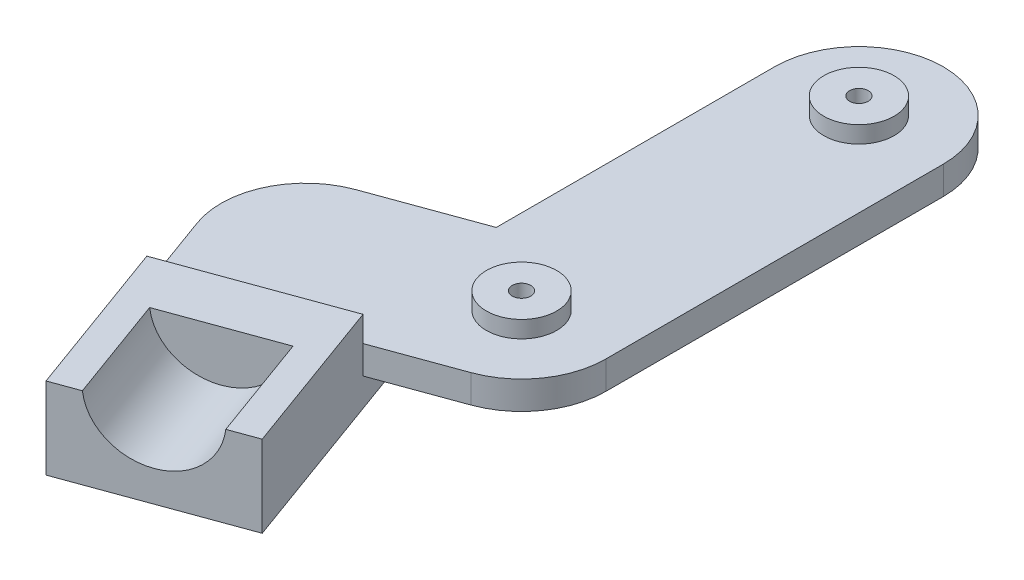
from build123d import *

# Parameters (mm, degrees)
EXTRUDE_1_DEPTH        = 5
SKETCH_2_R             = 6.25
EXTRUDE_2_DEPTH        = 3
HOLE_WIZARD_M4_1_D     = 3.3
HOLE_WIZARD_M4_1_DEPTH = 5
HOLE_WIZARD_M4_1_TIP   = 0.991420021
EXTRUDE_3_DEPTH        = 5
EXTRUDE_4_DEPTH        = 5
EXTRUDE_4_DEPTH_BACK   = 5
EXTRUDE_5_DEPTH        = 4.5
SKETCH_12_R            = 10
CUT_EXTRUDE_1_DEPTH    = 20


with BuildPart() as part:
    # 스케치1 → 보스-돌출1 (new body)
    with BuildSketch(Plane(origin=(0, 0, 0), x_dir=(1, 0, 0), z_dir=(0, 1, 0))):
        with BuildLine():
            Line((-15, 0), (-15, 60))
            ThreePointArc((-15, 60), (0, 75), (15, 60))
            Line((15, 60), (15, 0))
            ThreePointArc((15, 0), (0, -15), (-15, 0))
        make_face()
    extrude(amount=EXTRUDE_1_DEPTH)

    # 스케치2 → 보스-돌출2 (add)
    with BuildSketch(Plane(origin=(0, 5, 0), x_dir=(1, 0, 0), z_dir=(0, 1, 0))):
        with Locations((0, 60)):
            Circle(SKETCH_2_R)
        Circle(SKETCH_2_R)
    extrude(amount=EXTRUDE_2_DEPTH)

    # M4 탭을 위한 탭 드릴1
    with Locations(Plane(origin=(0, 8, 0), x_dir=(1, 0, 0), z_dir=(0, 1, 0))):
        with Locations((0, 0), (0, 60)):
            Hole(HOLE_WIZARD_M4_1_D / 2, depth=HOLE_WIZARD_M4_1_DEPTH)
            with Locations((0, 0, -(HOLE_WIZARD_M4_1_DEPTH + HOLE_WIZARD_M4_1_TIP / 2))):  # 118° drill point
                Cone(0, HOLE_WIZARD_M4_1_D / 2, HOLE_WIZARD_M4_1_TIP, mode=Mode.SUBTRACT)

    # 스케치9 → 보스-돌출3 (add)
    with BuildSketch(Plane.XZ):
        with BuildLine():
            Line((-5.13030215, -14.095389312), (-33.321080773, -3.834785012))
            ThreePointArc((-33.321080773, -3.834785012), (-42.286167935, 15.39090645), (-23.060476474, 24.355993612))
            Line((-23.060476474, 24.355993612), (5.13030215, 14.095389312))
            ThreePointArc((5.13030215, 14.095389312), (14.095389312, -5.13030215), (-5.13030215, -14.095389312))
        make_face()
    extrude(amount=-EXTRUDE_3_DEPTH)

    # 스케치10 → 보스-돌출4 (add, two sides: drawn at the far end of the back side and taken through both)
    with BuildSketch(Plane.XZ.offset(-EXTRUDE_4_DEPTH_BACK)):
        with BuildLine():
            Line((-42.286167935, 15.39090645), (-26.895261486, 57.677074385))
            Line((-26.895261486, 57.677074385), (1.295517138, 47.416470085))
            Line((1.295517138, 47.416470085), (-14.095389312, 5.13030215))
            ThreePointArc((-14.095389312, 5.13030215), (-33.321080773, -3.834785012), (-42.286167935, 15.39090645))
        make_face()
    extrude(amount=EXTRUDE_4_DEPTH + EXTRUDE_4_DEPTH_BACK)

    # 스케치11 → 보스-돌출5 (add)
    with BuildSketch(Plane(origin=(0, 5, 0), x_dir=(1, 0, 0), z_dir=(0, 1, 0))):
        Polygon((-26.895261486, -57.677074385), (-37.155865785, -29.486295761), (-8.965087162, -19.225691462), (1.295517138, -47.416470085), align=None)
    extrude(amount=EXTRUDE_5_DEPTH)

    # 스케치12 → 컷-돌출1 (cut)
    with BuildSketch(Plane(origin=(15.39090645, 0, 42.286167935), x_dir=(0.9396926207859109, 0, -0.342020143325662), z_dir=(0.342020143325662, 0, 0.9396926207859109))):
        with Locations((-30, 10.5)):
            Circle(SKETCH_12_R)
    extrude(amount=-CUT_EXTRUDE_1_DEPTH, mode=Mode.SUBTRACT)


solid = part.part
